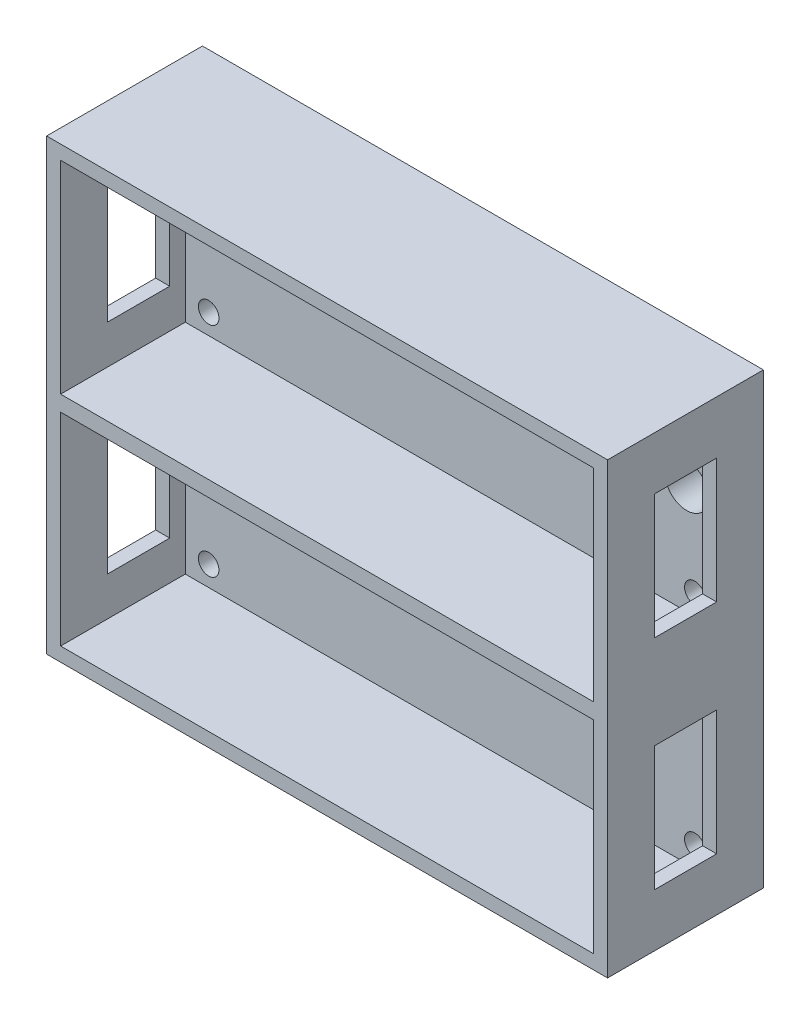
from build123d import *

# Parameters (mm, degrees)
SKETCH_1_W               = 90
SKETCH_1_H               = 72
EXTRUDE_1_DEPTH          = 25
SKETCH_2_W               = 85.5
SKETCH_2_H               = 32.5
CUT_EXTRUDE_1_DEPTH      = 20
SKETCH_3_W               = 10
SKETCH_3_H               = 20
CUT_EXTRUDE_2_DEPTH      = 1
CUT_EXTRUDE_2_DEPTH_BACK = 91
SKETCH_4_R               = 1.65
CUT_EXTRUDE_3_DEPTH      = 21
CUT_EXTRUDE_3_DEPTH_BACK = 6
SKETCH_5_R               = 3.5
CUT_EXTRUDE_4_DEPTH      = 1
CUT_EXTRUDE_4_DEPTH_BACK = 26


with BuildPart() as part:
    # 草图1 → 凸台-拉伸1 (new body)
    with BuildSketch(Plane.XY):
        Rectangle(SKETCH_1_W, SKETCH_1_H)
    extrude(amount=EXTRUDE_1_DEPTH)

    # 草图2 → 切除-拉伸1 (cut)
    with BuildSketch(Plane.XY.offset(25)):
        with Locations((0, 17.5)):
            Rectangle(SKETCH_2_W, SKETCH_2_H)
        with Locations((0, -17.5)):
            Rectangle(SKETCH_2_W, SKETCH_2_H)
    extrude(amount=-CUT_EXTRUDE_1_DEPTH, mode=Mode.SUBTRACT)

    # 草图3 → 切除-拉伸2 (cut, two sides)
    with BuildSketch(Plane(origin=(45, 0, 0), x_dir=(0, 0, -1), z_dir=(1, 0, 0))) as cut_extrude_2_sk:
        with Locations((-12.5, 17.5)):
            Rectangle(SKETCH_3_W, SKETCH_3_H)
        with Locations((-12.5, -17.5)):
            Rectangle(SKETCH_3_W, SKETCH_3_H)
    extrude(amount=CUT_EXTRUDE_2_DEPTH, mode=Mode.SUBTRACT)
    extrude(cut_extrude_2_sk.sketch, amount=-CUT_EXTRUDE_2_DEPTH_BACK, mode=Mode.SUBTRACT)

    # 草图4 → 切除-拉伸3 (cut, two sides)
    with BuildSketch(Plane.XY.offset(5)) as cut_extrude_3_sk:
        with Locations((-39, 4.5)):
            Circle(SKETCH_4_R)
        with Locations((-39, 30.5)):
            Circle(SKETCH_4_R)
        with Locations((-39, -4.5)):
            Circle(SKETCH_4_R)
        with Locations((-39, -30.5)):
            Circle(SKETCH_4_R)
        with Locations((39, -30.5)):
            Circle(SKETCH_4_R)
        with Locations((39, -4.5)):
            Circle(SKETCH_4_R)
        with Locations((39, 4.5)):
            Circle(SKETCH_4_R)
        with Locations((39, 30.5)):
            Circle(SKETCH_4_R)
    extrude(amount=CUT_EXTRUDE_3_DEPTH, mode=Mode.SUBTRACT)
    extrude(cut_extrude_3_sk.sketch, amount=-CUT_EXTRUDE_3_DEPTH_BACK, mode=Mode.SUBTRACT)

    # 草图5 → 切除-拉伸4 (cut, two sides)
    with BuildSketch(Plane(origin=(0, 0, 0), x_dir=(-1, 0, 0), z_dir=(0, 0, -1))) as cut_extrude_4_sk:
        with Locations((-37.7, 18.8)):
            Circle(SKETCH_5_R)
    extrude(amount=CUT_EXTRUDE_4_DEPTH, mode=Mode.SUBTRACT)
    extrude(cut_extrude_4_sk.sketch, amount=-CUT_EXTRUDE_4_DEPTH_BACK, mode=Mode.SUBTRACT)


solid = part.part
